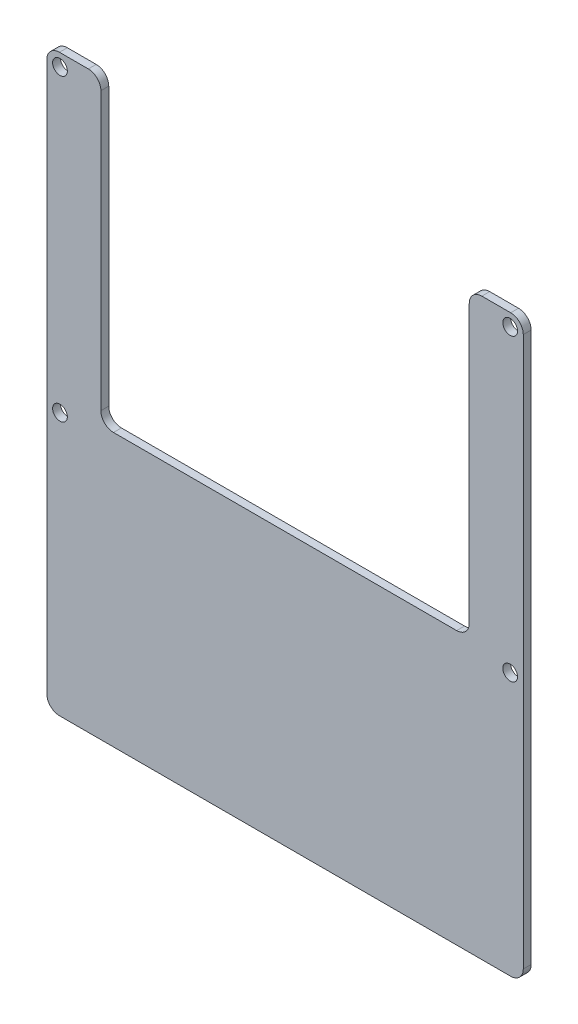
from build123d import *

# Parameters (mm, degrees)
SKETCH1_R   = 1.5
BOARD_DEPTH = 1.6
FILLET1_R   = 2.56


with BuildPart() as part:
    # Sketch1 → Board (new body)
    with BuildSketch(Plane.XY):
        Polygon((20, 20), (117, 20), (117, 137), (106, 137), (106, 75.46), (31, 75.46), (31, 137), (20, 137), align=None)
        with Locations((22.6657, 134.46)):
            Circle(SKETCH1_R, mode=Mode.SUBTRACT)
        with Locations((114.3343, 134.46)):
            Circle(SKETCH1_R, mode=Mode.SUBTRACT)
        with Locations((22.6657, 73.5)):
            Circle(SKETCH1_R, mode=Mode.SUBTRACT)
        with Locations((114.3343, 73.5)):
            Circle(SKETCH1_R, mode=Mode.SUBTRACT)
    extrude(amount=BOARD_DEPTH)

    # Fillet1
    fillet1_edges = [part.edges().sort_by_distance(p)[0] for p in [
        (20, 137, 0.8),
        (31, 137, 0.8),
        (31, 75.46, 0.8),
        (106, 75.46, 0.8),
        (106, 137, 0.8),
        (117, 137, 0.8),
        (117, 20, 0.8),
        (20, 20, 0.8),
    ]]
    fillet(fillet1_edges, radius=FILLET1_R)


solid = part.part
